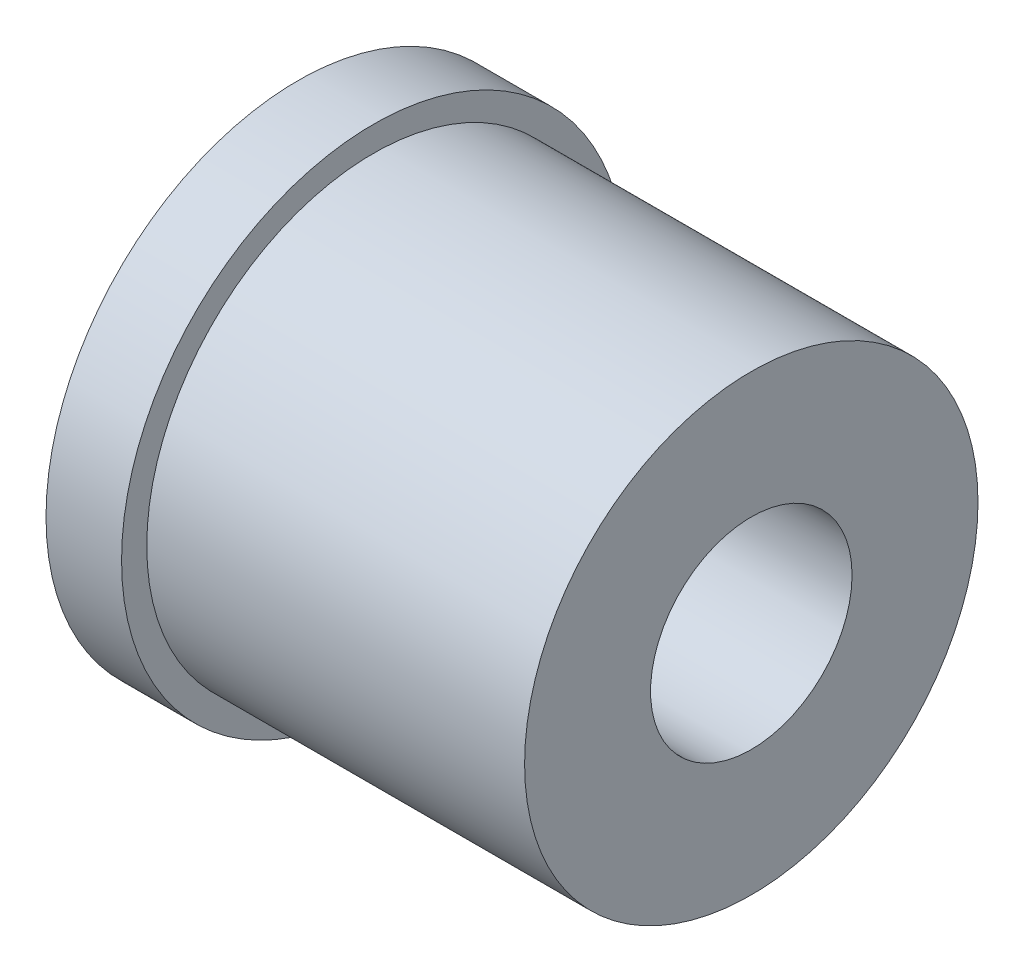
from build123d import *

# Parameters (mm, degrees)
SKETCH1_R           = 2.25
SKETCH1_R_2         = 1
BOSS_EXTRUDE1_DEPTH = 4.5
SKETCH2_R           = 2.5
SKETCH2_R_2         = 2.25
BOSS_EXTRUDE2_DEPTH = 0.75


with BuildPart() as part:
    # Sketch1 → Boss-Extrude1 (new body)
    with BuildSketch(Plane(origin=(0, 0, 0), x_dir=(0, 0, -1), z_dir=(1, 0, 0))):
        Circle(SKETCH1_R)
        Circle(SKETCH1_R_2, mode=Mode.SUBTRACT)
    extrude(amount=BOSS_EXTRUDE1_DEPTH)

    # Sketch2 → Boss-Extrude2 (add)
    with BuildSketch(Plane.ZY):
        Circle(SKETCH2_R)
        Circle(SKETCH2_R_2, mode=Mode.SUBTRACT)
    extrude(amount=-BOSS_EXTRUDE2_DEPTH)


solid = part.part
